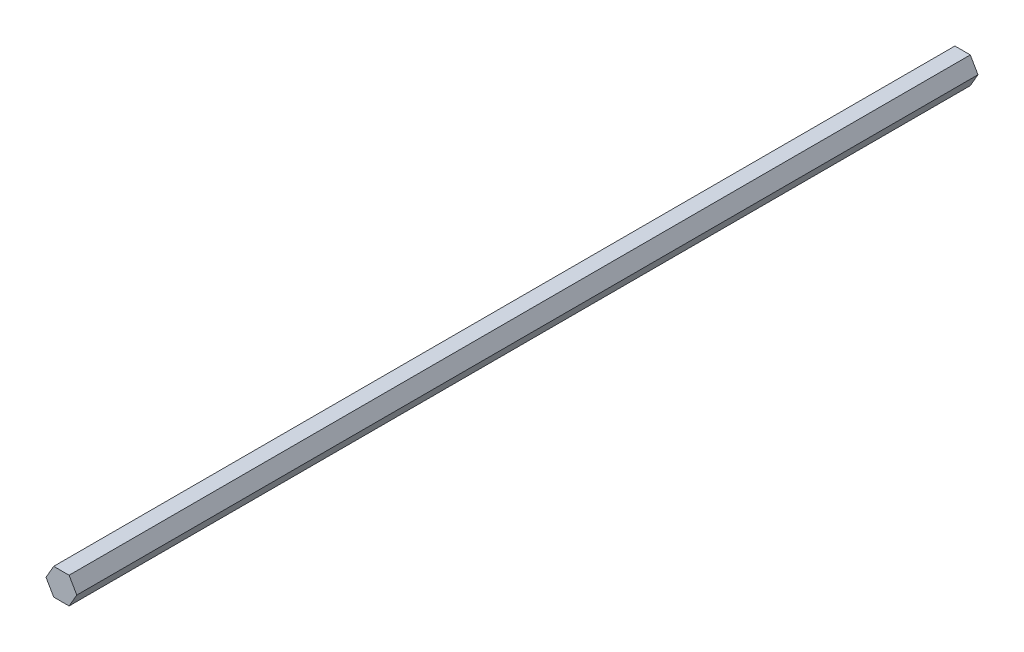
from build123d import *

# Parameters (mm, degrees)
BOSS_EXTRUDE1_DEPTH = 423.18


with BuildPart() as part:
    # Sketch1 → Boss-Extrude1 (new body)
    with BuildSketch(Plane.XY):
        Polygon((-3.615, 6.261363669), (-7.23, 0), (-3.615, -6.261363669), (3.615, -6.261363669), (7.23, 0), (3.615, 6.261363669), align=None)
    extrude(amount=BOSS_EXTRUDE1_DEPTH)


solid = part.part
